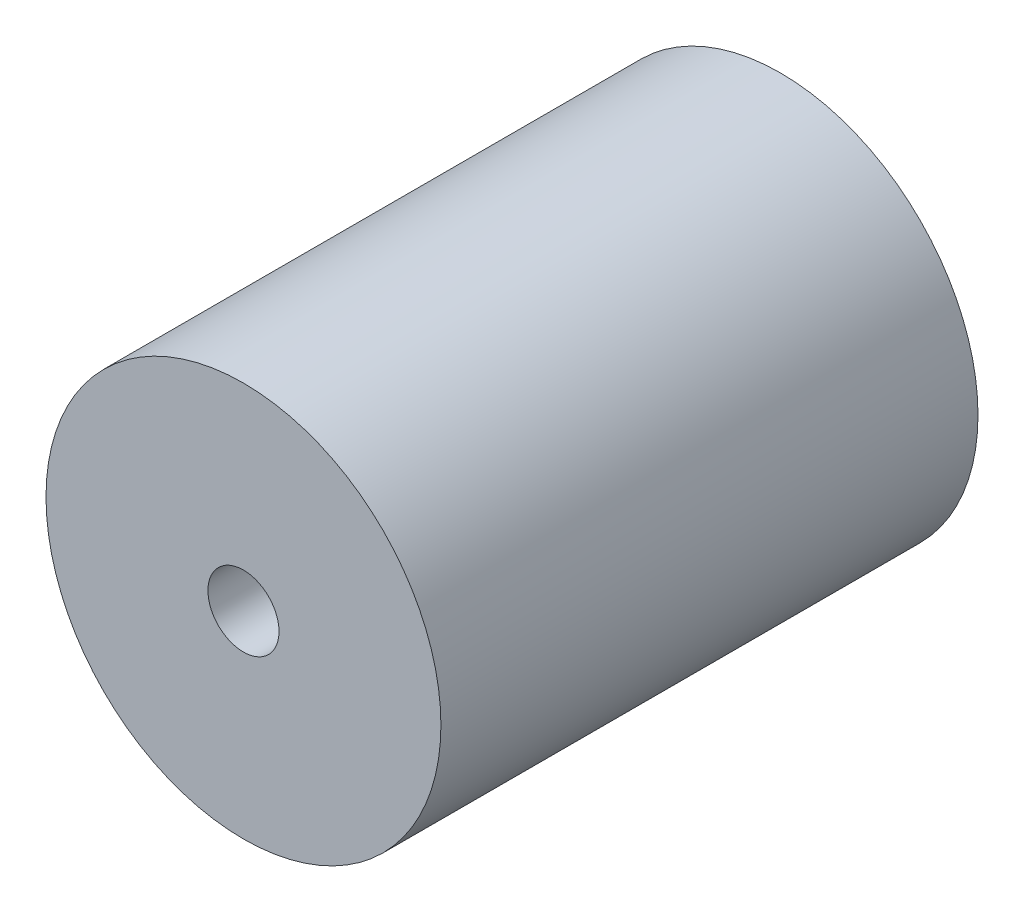
from build123d import *

# Parameters (mm, degrees)
SKETCH_1_R          = 12.5
EXTRUDE_1_DEPTH     = 34
SKETCH_2_R          = 2.25
CUT_EXTRUDE_1_DEPTH = 11
SKETCH_3_R          = 4
CUT_EXTRUDE_2_DEPTH = 11


with BuildPart() as part:
    # 草图1 → 凸台-拉伸1 (new body)
    with BuildSketch(Plane.XY):
        Circle(SKETCH_1_R)
    extrude(amount=EXTRUDE_1_DEPTH)

    # 草图2 → 切除-拉伸1 (cut)
    with BuildSketch(Plane.XY.offset(34)):
        Circle(SKETCH_2_R)
    extrude(amount=-CUT_EXTRUDE_1_DEPTH, mode=Mode.SUBTRACT)

    # 草图3 → 切除-拉伸2 (cut)
    with BuildSketch(Plane(origin=(0, 0, 0), x_dir=(-1, 0, 0), z_dir=(0, 0, -1))):
        Circle(SKETCH_3_R)
    extrude(amount=-CUT_EXTRUDE_2_DEPTH, mode=Mode.SUBTRACT)


solid = part.part
